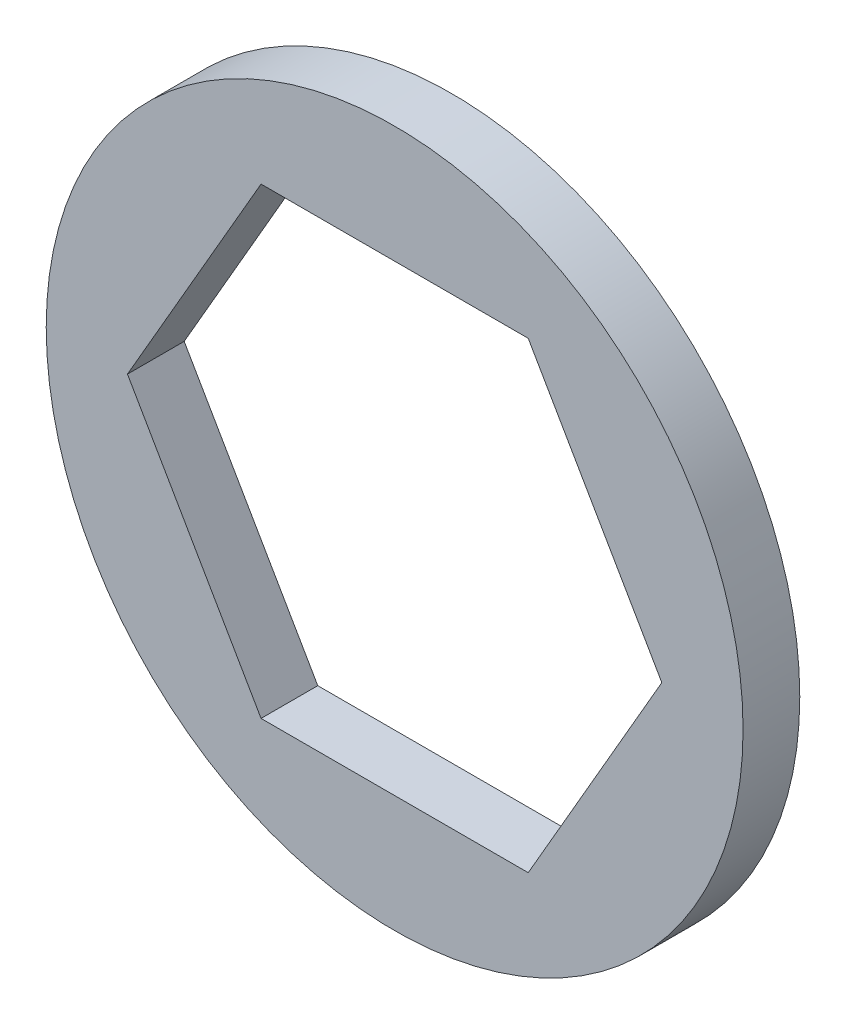
from build123d import *

# Parameters (mm, degrees)
SKETCH1_R           = 9.7536
BOSS_EXTRUDE1_DEPTH = 1.5875


with BuildPart() as part:
    # Sketch1 → Boss-Extrude1 (new body)
    with BuildSketch(Plane.XY):
        Circle(SKETCH1_R)
        Polygon((7.478995387, 0), (3.739497694, 6.477), (-3.739497694, 6.477), (-7.478995387, 0), (-3.739497694, -6.477), (3.739497694, -6.477), align=None, mode=Mode.SUBTRACT)
    extrude(amount=BOSS_EXTRUDE1_DEPTH)


solid = part.part
